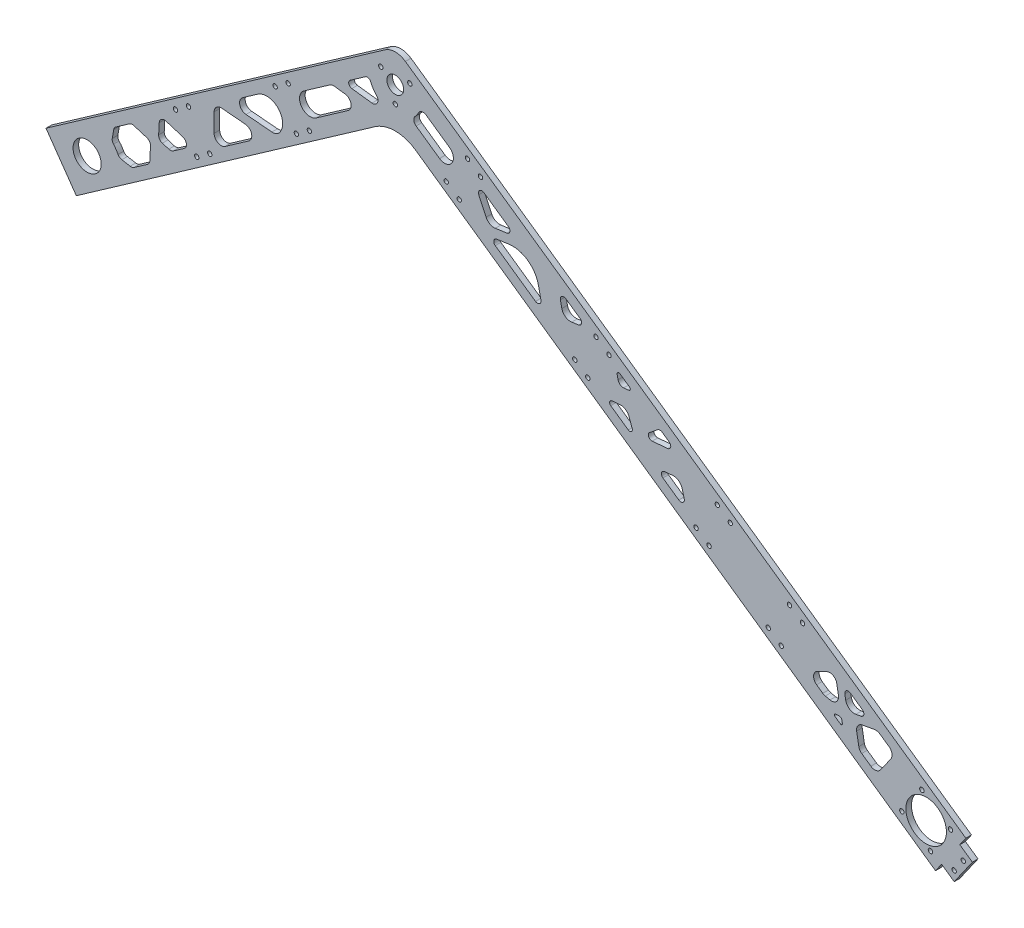
from build123d import *

# Parameters (mm, degrees)
SKETCH2_R                    = 7.9756
SKETCH2_R_2                  = 4.7625
BASE_DEPTH                   = 3.175
FILLET1_R                    = 20
FILLET2_R                    = 10
LIGHTENING_HOLES_DEPTH       = 4.175
SKETCH6_R                    = 1.25
SHAFT_CONNECTION_DEPTH       = 4.175
SKETCH8_R                    = 1.25
FRAME_SUPPORTS_DEPTH         = 4.175
SKETCH3_R                    = 1.25
SKETCH3_R_2                  = 11.5
MOTOR_PLATE_CONNECTION_DEPTH = 4.175
SKETCH12_R                   = 1.25
EXTRA_SUPPORT_MATERIAL_DEPTH = 3.175


with BuildPart() as part:
    # Sketch2 → Base (new body)
    with BuildSketch(Plane.XY):
        Polygon((0, 0), (-17.207293091, 24.574561329), (-9.015772648, 30.310325692), (180.953522494, 163.328258179), (504.65033424, -63.3266895), (487.44304115, -87.901250829), (180.953522494, 126.705020516), align=None)
        with Locations((6.121102942, 22.597661254)):
            Circle(SKETCH2_R, mode=Mode.SUBTRACT)
        with Locations((180.953522494, 145.016639348)):
            Circle(SKETCH2_R_2, mode=Mode.SUBTRACT)
    extrude(amount=BASE_DEPTH)

    # Fillet1
    fillet1_edges = [part.edges().sort_by_distance(p)[0] for p in [
        (180.953522494, 126.705020516, 1.5875),
    ]]
    fillet(fillet1_edges, radius=FILLET1_R)

    # Fillet2
    fillet2_edges = [part.edges().sort_by_distance(p)[0] for p in [
        (180.953522494, 163.328258179, 1.5875),
    ]]
    fillet(fillet2_edges, radius=FILLET2_R)

    # Sketch5 → Lightening Holes (cut, through all)
    with BuildSketch(Plane.XY.offset(3.175)):
        with BuildLine():
            Line((21.221933831, 43.085678378), (20.389165903, 38.362816767))
            ThreePointArc((20.389165903, 38.362816767), (20.456316842, 37.027219823), (21.097177916, 35.853496888))
            ThreePointArc((21.097177916, 35.853496888), (22.504143828, 34.069189981), (23.699633179, 32.136805591))
            ThreePointArc((23.699633179, 32.136805591), (24.583384564, 31.133156283), (25.815468182, 30.613253983))
            Line((25.815468182, 30.613253983), (30.538329794, 29.780486055))
            ThreePointArc((30.538329794, 29.780486055), (31.708593168, 29.806021292), (32.780003636, 30.277453181))
            Line((32.780003636, 30.277453181), (40.393335067, 35.60836524))
            ThreePointArc((40.393335067, 35.60836524), (41.296464879, 36.611392512), (41.668494362, 37.908813504))
            Line((41.668494362, 37.908813504), (42.066986053, 45.512487922))
            ThreePointArc((42.066986053, 45.512487922), (41.528553581, 47.3902251), (39.948212563, 48.538410059))
            Line((39.948212563, 48.538410059), (32.666803636, 50.764560172))
            ThreePointArc((32.666803636, 50.764560172), (31.320385127, 50.858710926), (30.068959213, 50.353102037))
            Line((30.068959213, 50.353102037), (22.455627781, 45.022189978))
            ThreePointArc((22.455627781, 45.022189978), (21.646182753, 44.17663267), (21.221933831, 43.085678378))
        make_face()
        with BuildLine():
            Line((46.698324267, 53.264889158), (47.017103083, 59.347551311))
            ThreePointArc((47.017103083, 59.347551311), (48.292262378, 61.647999576), (50.890106801, 62.059457711))
            Line((50.890106801, 62.059457711), (60.355672781, 59.165543773))
            ThreePointArc((60.355672781, 59.165543773), (62.441622689, 56.7659329), (61.199286976, 53.839173372))
            Line((61.199286976, 53.839173372), (55.055646644, 49.5373501))
            ThreePointArc((55.055646644, 49.5373501), (53.80422073, 49.031741211), (52.45780222, 49.125891965))
            Line((52.45780222, 49.125891965), (48.817097757, 50.238967021))
            ThreePointArc((48.817097757, 50.238967021), (47.236756738, 51.38715198), (46.698324267, 53.264889158))
        make_face()
        with BuildLine():
            Line((143.729636686, 126.276841436), (129.176143076, 116.086375503))
            ThreePointArc((129.176143076, 116.086375503), (127.702689428, 107.730004619), (136.059060312, 106.256550971))
            Line((136.059060312, 106.256550971), (154.25159597, 118.995101578))
            ThreePointArc((154.25159597, 118.995101578), (155.838473129, 123.239397337), (152.444767598, 126.241894361))
            Line((152.444767598, 126.241894361), (146.511419805, 126.970417865))
            ThreePointArc((146.511419805, 126.970417865), (145.056254849, 126.881416163), (143.729636686, 126.276841436))
        make_face()
        with BuildLine():
            Line((82.511657948, 84.258042008), (95.885266773, 83.088002846))
            ThreePointArc((95.885266773, 83.088002846), (99.400347108, 80.138500234), (97.830949548, 75.826615876))
            Line((97.830949548, 75.826615876), (84.457340722, 66.462314163))
            ThreePointArc((84.457340722, 66.462314163), (80.316040524, 66.190879008), (78.163034977, 69.738922341))
            Line((78.163034977, 69.738922341), (78.163034977, 80.273263216))
            ThreePointArc((78.163034977, 80.273263216), (79.460674146, 83.222372563), (82.511657948, 84.258042008))
        make_face()
        with BuildLine():
            Line((163.977450858, 140.454513551), (155.376354393, 134.431960969))
            ThreePointArc((155.376354393, 134.431960969), (154.582915813, 132.309813089), (156.279768578, 130.808564577))
            Line((156.279768578, 130.808564577), (167.764073452, 129.398469246))
            ThreePointArc((167.764073452, 129.398469246), (170.824941709, 131.053135413), (170.269520523, 134.488006869))
            ThreePointArc((170.269520523, 134.488006869), (168.371424711, 136.850194872), (166.986829467, 139.545671802))
            ThreePointArc((166.986829467, 139.545671802), (165.70281704, 140.730803249), (163.977450858, 140.454513551))
        make_face()
        with BuildLine():
            Line((110.951708103, 86.788959217), (96.256849142, 88.074592789))
            ThreePointArc((96.256849142, 88.074592789), (92.741768808, 91.024095401), (94.311166367, 95.335979758))
            Line((94.311166367, 95.335979758), (102.880852438, 101.336538545))
            ThreePointArc((102.880852438, 101.336538545), (114.310102984, 100.423576167), (115.56804488, 89.02713591))
            ThreePointArc((115.56804488, 89.02713591), (113.568817103, 87.270844114), (110.951708103, 86.788959217))
        make_face()
        with BuildLine():
            Line((206.053240505, 121.337754646), (192.739077552, 130.66043191))
            ThreePointArc((192.739077552, 130.66043191), (191.480974333, 132.762139857), (192.208759467, 135.101013261))
            ThreePointArc((192.208759467, 135.101013261), (193.240803159, 136.412992802), (194.120680921, 137.831520075))
            ThreePointArc((194.120680921, 137.831520075), (196.069585824, 139.315356211), (198.474841916, 138.851952353))
            Line((198.474841916, 138.851952353), (211.789004869, 129.529275088))
            ThreePointArc((211.789004869, 129.529275088), (213.016882908, 122.565632685), (206.053240505, 121.337754646))
        make_face()
        with BuildLine():
            Line((228.302122348, 114.631447549), (232.466025934, 105.701927492))
            ThreePointArc((232.466025934, 105.701927492), (234.611771068, 103.420933238), (237.693430374, 102.863678457))
            Line((237.693430374, 102.863678457), (244.259856406, 103.786529453))
            ThreePointArc((244.259856406, 103.786529453), (245.926250045, 105.300174862), (245.128663077, 107.405369679))
            Line((245.128663077, 107.405369679), (231.261890794, 117.114988161))
            ThreePointArc((231.261890794, 117.114988161), (228.829162702, 117.008772959), (228.302122348, 114.631447549))
        make_face()
        with BuildLine():
            Line((238.541010302, 97.933660185), (245.387921464, 98.895930795))
            ThreePointArc((245.387921464, 98.895930795), (256.079164523, 96.329190428), (262.147731989, 87.160585126))
            Line((262.147731989, 87.160585126), (263.585274935, 80.397477301))
            ThreePointArc((263.585274935, 80.397477301), (262.732853704, 78.313882275), (260.481826861, 78.34334983))
            Line((260.481826861, 78.34334983), (237.672203631, 94.314819959))
            ThreePointArc((237.672203631, 94.314819959), (236.874616663, 96.420014775), (238.541010302, 97.933660185))
        make_face()
        with BuildLine():
            Line((274.622381825, 86.188784042), (275.440182374, 82.341334954))
            ThreePointArc((275.440182374, 82.341334954), (277.463038196, 79.285133187), (281.026785882, 78.429553064))
            Line((281.026785882, 78.429553064), (284.92190966, 78.976977011))
            ThreePointArc((284.92190966, 78.976977011), (286.588303299, 80.490622421), (285.790716331, 82.595817237))
            Line((285.790716331, 82.595817237), (277.725829899, 88.242911512))
            ThreePointArc((277.725829899, 88.242911512), (275.474803056, 88.272379067), (274.622381825, 86.188784042))
        make_face()
        with BuildLine():
            Line((313.848740225, 62.9493774), (308.349056051, 66.800297715))
            ThreePointArc((308.349056051, 66.800297715), (307.22354263, 66.815031493), (306.797332014, 65.77323398))
            Line((306.797332014, 65.77323398), (307.333443599, 63.251027278))
            ThreePointArc((307.333443599, 63.251027278), (308.483418041, 61.463191769), (310.529353629, 60.886178257))
            Line((310.529353629, 60.886178257), (313.362319531, 61.134030657))
            ThreePointArc((313.362319531, 61.134030657), (314.241089615, 61.87140631), (313.848740225, 62.9493774))
        make_face()
        with BuildLine():
            Line((313.106290368, 41.495303789), (303.177027604, 48.447848425))
            ThreePointArc((303.177027604, 48.447848425), (302.588503519, 50.064805059), (303.906658644, 51.170868538))
            Line((303.906658644, 51.170868538), (308.401647912, 51.564129142))
            ThreePointArc((308.401647912, 51.564129142), (311.523924668, 50.800112881), (313.53588973, 48.293256368))
            Line((313.53588973, 48.293256368), (315.376193953, 43.23706207))
            ThreePointArc((315.376193953, 43.23706207), (314.879797166, 41.534001845), (313.106290368, 41.495303789))
        make_face()
        with BuildLine():
            Line((325.28241676, 46.34148234), (329.882929868, 49.980403215))
            ThreePointArc((329.882929868, 49.980403215), (331.065330871, 50.410937491), (332.270827857, 50.05009277))
            Line((332.270827857, 50.05009277), (336.379554197, 47.173131614))
            ThreePointArc((336.379554197, 47.173131614), (337.164252977, 45.017189436), (335.406712809, 43.54243813))
            Line((335.406712809, 43.54243813), (326.697473362, 42.78047841))
            ThreePointArc((326.697473362, 42.78047841), (324.664531354, 44.034293111), (325.28241676, 46.34148234))
        make_face()
        with BuildLine():
            Line((344.87592703, 23.561849069), (343.667493871, 28.071783014))
            ThreePointArc((343.667493871, 28.071783014), (341.705746922, 30.87344801), (338.402086026, 31.758661279))
            Line((338.402086026, 31.758661279), (333.750825896, 31.351728746))
            ThreePointArc((333.750825896, 31.351728746), (331.993285729, 29.87697744), (332.777984509, 27.721035261))
            Line((332.777984509, 27.721035261), (341.796922504, 21.40590689))
            ThreePointArc((341.796922504, 21.40590689), (344.09122825, 21.40590689), (344.87592703, 23.561849069))
        make_face()
        with BuildLine():
            Line((462.052727884, -45.707270307), (456.31696352, -53.89879075))
            ThreePointArc((456.31696352, -53.89879075), (453.734948054, -55.543716017), (450.746049598, -54.881093182))
            Line((450.746049598, -54.881093182), (445.550048789, -51.242814247))
            ThreePointArc((445.550048789, -51.242814247), (444.470788751, -50.115404503), (443.905123522, -48.66079878))
            Line((443.905123522, -48.66079878), (442.677245483, -41.697156377))
            ThreePointArc((442.677245483, -41.697156377), (443.339868317, -38.708257921), (445.921883784, -37.063332655))
            Line((445.921883784, -37.063332655), (452.885526187, -35.835454615))
            ThreePointArc((452.885526187, -35.835454615), (454.445877354, -35.869501598), (455.874424643, -36.49807745))
            Line((455.874424643, -36.49807745), (461.070425452, -40.136356385))
            ThreePointArc((461.070425452, -40.136356385), (462.715350719, -42.718371851), (462.052727884, -45.707270307))
        make_face()
        with BuildLine():
            Line((445.128312908, -33.141554164), (442.272867814, -33.645046175))
            ThreePointArc((442.272867814, -33.645046175), (438.536744744, -32.816767632), (436.480588161, -29.589248299))
            Line((436.480588161, -29.589248299), (435.977096149, -26.733803205))
            ThreePointArc((435.977096149, -26.733803205), (436.872112438, -24.699723958), (439.093864528, -24.748202761))
            Line((439.093864528, -24.748202761), (445.928169425, -29.533634569))
            ThreePointArc((445.928169425, -29.533634569), (446.733608567, -31.604817885), (445.128312908, -33.141554164))
        make_face()
        with BuildLine():
            Line((430.750665545, -39.214593597), (432.857440341, -39.214593597))
            ThreePointArc((432.857440341, -39.214593597), (433.821621756, -39.565526933), (434.334651971, -40.454121331))
            Line((434.334651971, -40.454121331), (434.610767959, -42.020052913))
            ThreePointArc((434.610767959, -42.020052913), (434.27513685, -42.782832631), (433.441979817, -42.764653079))
            Line((433.441979817, -42.764653079), (430.320483218, -40.578957631))
            ThreePointArc((430.320483218, -40.578957631), (430.035377832, -39.739064248), (430.750665545, -39.214593597))
        make_face()
        with BuildLine():
            Line((431.410035699, -23.867798241), (432.373975859, -29.334574541))
            ThreePointArc((432.373975859, -29.334574541), (431.205825445, -32.913801079), (427.582594956, -33.937343369))
            Line((427.582594956, -33.937343369), (424.898144224, -33.352018059))
            ThreePointArc((424.898144224, -33.352018059), (424.145686598, -33.107888164), (423.455988369, -32.720450119))
            Line((423.455988369, -32.720450119), (419.959108305, -30.271908338))
            ThreePointArc((419.959108305, -30.271908338), (418.268635258, -26.64667719), (420.562941004, -23.370069013))
            Line((420.562941004, -23.370069013), (425.78033164, -20.937159804))
            ThreePointArc((425.78033164, -20.937159804), (429.31779914, -21.014347619), (431.410035699, -23.867798241))
        make_face()
    extrude(amount=-LIGHTENING_HOLES_DEPTH, mode=Mode.SUBTRACT)

    # Sketch6 → Shaft Connection (cut, through all)
    with BuildSketch(Plane.XY.offset(3.175)):
        with Locations((180.953522494, 135.504139348)):
            Circle(SKETCH6_R)
        with Locations((172.715455841, 149.772889348)):
            Circle(SKETCH6_R)
        with Locations((189.191589148, 149.772889348)):
            Circle(SKETCH6_R)
    extrude(amount=-SHAFT_CONNECTION_DEPTH, mode=Mode.SUBTRACT)

    # Sketch8 → Frame Supports (cut, through all)
    with BuildSketch(Plane.XY.offset(3.175)):
        with Locations((411.962515405, -3.919465701)):
            Circle(SKETCH8_R)
        with Locations((363.632544792, 29.921544044)):
            Circle(SKETCH8_R)
        with Locations((112.790897887, 110.106788955)):
            Circle(SKETCH8_R)
        with Locations((404.590147006, 1.242722226)):
            Circle(SKETCH8_R)
        with Locations((371.00491319, 24.759356117)):
            Circle(SKETCH8_R)
        with Locations((120.163266286, 115.268976882)):
            Circle(SKETCH8_R)
        with Locations((392.545041843, -15.959470704)):
            Circle(SKETCH8_R)
        with Locations((399.917410241, -21.121658631)):
            Circle(SKETCH8_R)
        with Locations((302.19614147, 72.93977677)):
            Circle(SKETCH8_R)
        with Locations((294.823773072, 78.101964697)):
            Circle(SKETCH8_R)
        with Locations((63.64177523, 75.692202774)):
            Circle(SKETCH8_R)
        with Locations((56.269406831, 70.530014847)):
            Circle(SKETCH8_R)
        with Locations((68.314511994, 53.327821917)):
            Circle(SKETCH8_R)
        with Locations((75.686880393, 58.490009844)):
            Circle(SKETCH8_R)
        with Locations((282.778667908, 60.899771767)):
            Circle(SKETCH8_R)
        with Locations((290.151036307, 55.73758384)):
            Circle(SKETCH8_R)
        with Locations((351.587439628, 12.719351114)):
            Circle(SKETCH8_R)
        with Locations((358.959808027, 7.557163187)):
            Circle(SKETCH8_R)
        with Locations((124.83600305, 92.904596025)):
            Circle(SKETCH8_R)
        with Locations((132.208371449, 98.066783952)):
            Circle(SKETCH8_R)
        with Locations((221.91924113, 129.150267533)):
            Circle(SKETCH8_R)
        with Locations((229.291609528, 123.988079606)):
            Circle(SKETCH8_R)
        with Locations((209.874135966, 111.948074603)):
            Circle(SKETCH8_R)
        with Locations((217.246504365, 106.785886676)):
            Circle(SKETCH8_R)
    extrude(amount=-FRAME_SUPPORTS_DEPTH, mode=Mode.SUBTRACT)

    # Sketch3 → Motor Plate Connection (cut, through all)
    with BuildSketch(Plane.XY.offset(3.175)):
        with Locations((495.908411484, -63.432096259)):
            Circle(SKETCH3_R)
        with Locations((479.690028455, -52.075862204)):
            Circle(SKETCH3_R)
        with Locations((484.552177429, -79.650479289)):
            Circle(SKETCH3_R)
        with Locations((468.3337944, -68.294245234)):
            Circle(SKETCH3_R)
        with Locations((482.121102942, -65.863170746)):
            Circle(SKETCH3_R_2)
    extrude(amount=-MOTOR_PLATE_CONNECTION_DEPTH, mode=Mode.SUBTRACT)

    # Sketch12 → Extra Support Material (add)
    with BuildSketch(Plane.XY.offset(3.175)):
        Polygon((490.884499768, -82.986338563), (501.208875622, -68.241601766), (508.360472008, -73.249203466), (498.036096154, -87.993940263), align=None)
        with Locations((498.016382377, -82.486650878)):
            Circle(SKETCH12_R, mode=Mode.SUBTRACT)
        with Locations((503.178570304, -75.114282479)):
            Circle(SKETCH12_R, mode=Mode.SUBTRACT)
    extrude(amount=-EXTRA_SUPPORT_MATERIAL_DEPTH)


solid = part.part
